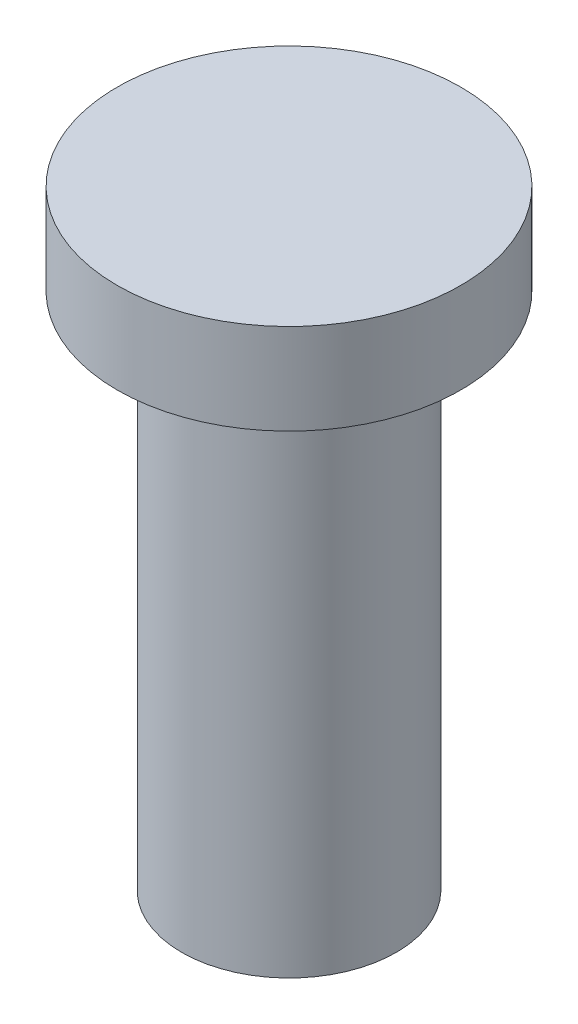
from build123d import *

# Parameters (mm, degrees)
SKETCH1_R           = 3.96875
BOSS_EXTRUDE1_DEPTH = 20
SKETCH2_R           = 1.675
CUT_EXTRUDE1_DEPTH  = 12
SKETCH4_R           = 6.35
BOSS_EXTRUDE2_DEPTH = 2.54
SKETCH6_R           = 6.35
BOSS_EXTRUDE3_DEPTH = 3.35


with BuildPart() as part:
    # Sketch1 → Boss-Extrude1 (new body)
    with BuildSketch(Plane(origin=(0, 0, 0), x_dir=(1, 0, 0), z_dir=(0, 1, 0))):
        Circle(SKETCH1_R)
    extrude(amount=BOSS_EXTRUDE1_DEPTH)

    # Sketch2 → Cut-Extrude1 (cut)
    with BuildSketch(Plane.XZ):
        Circle(SKETCH2_R)
    extrude(amount=-CUT_EXTRUDE1_DEPTH, mode=Mode.SUBTRACT)

    # Sketch4 → Boss-Extrude2 (add)
    with BuildSketch(Plane(origin=(0, 20, 0), x_dir=(1, 0, 0), z_dir=(0, 1, 0))):
        Circle(SKETCH4_R)
    extrude(amount=BOSS_EXTRUDE2_DEPTH)

    # Sketch6 → Boss-Extrude3 (add)
    with BuildSketch(Plane(origin=(0, 22.54, 0), x_dir=(1, 0, 0), z_dir=(0, 1, 0))):
        Circle(SKETCH6_R)
    extrude(amount=-BOSS_EXTRUDE3_DEPTH)


solid = part.part
